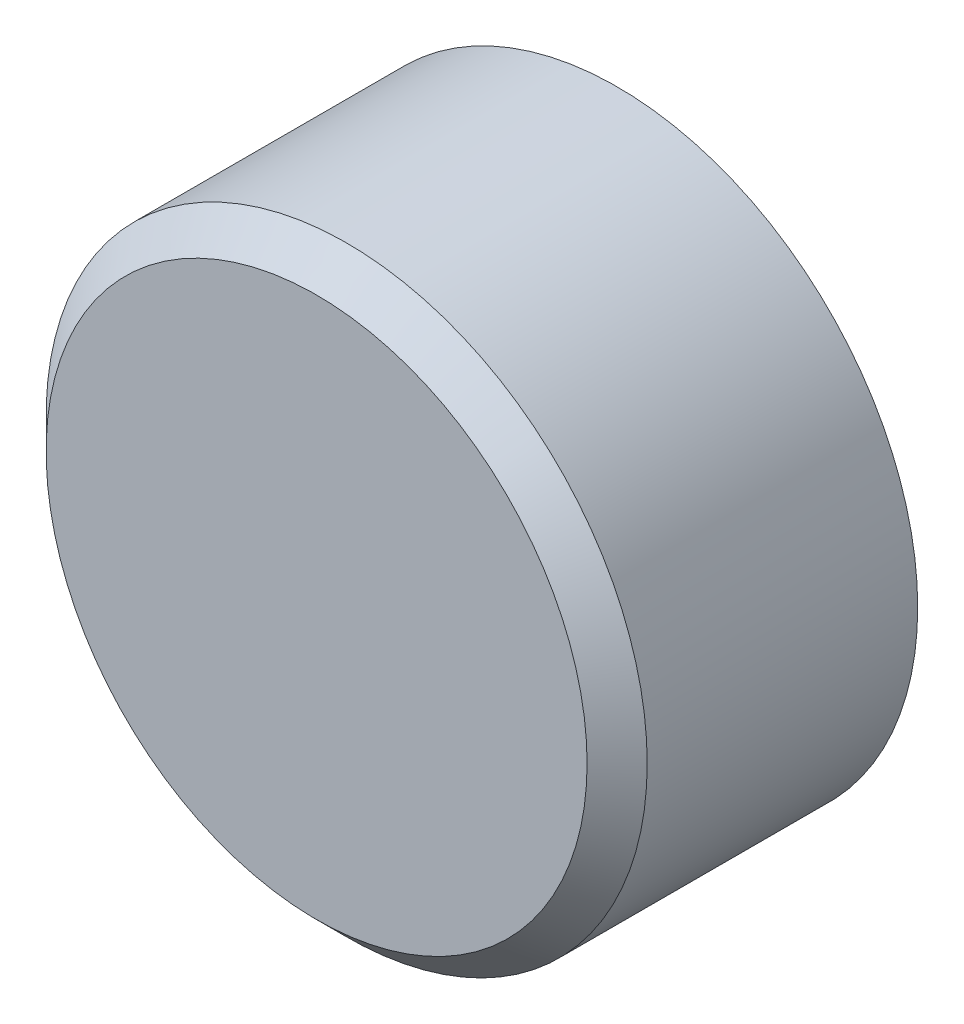
from build123d import *

# Parameters (mm, degrees)
ESQUISSE1_R        = 20
BOSS_EXTRU_1_DEPTH = 20
CHANFREIN1_SIZE    = 2


with BuildPart() as part:
    # Esquisse1 → Boss.-Extru.1 (new body)
    with BuildSketch(Plane.XY):
        Circle(ESQUISSE1_R)
    extrude(amount=BOSS_EXTRU_1_DEPTH)

    # Chanfrein1
    chanfrein1_edges = [part.edges().sort_by_distance(p)[0] for p in [
        (-20, 0, 20),
    ]]
    chamfer(chanfrein1_edges, length=CHANFREIN1_SIZE)


solid = part.part
